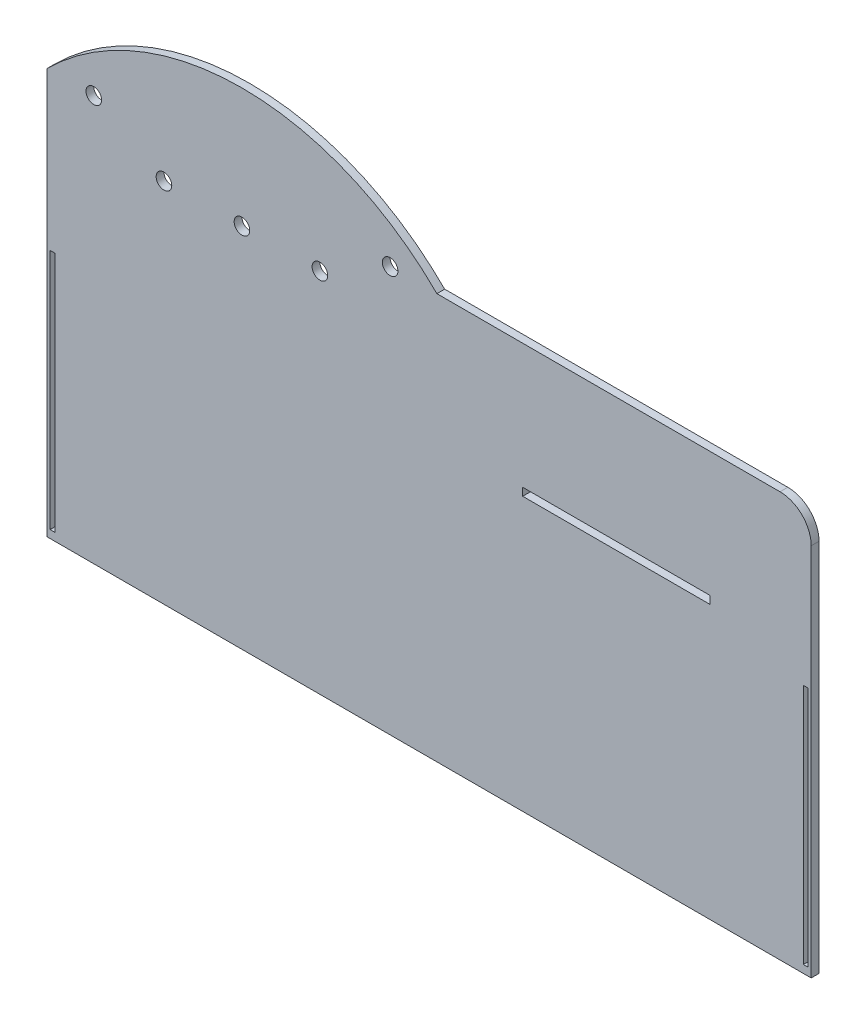
from build123d import *

# Parameters (mm, degrees)
SALIENTE_EXTRUIR1_DEPTH = 6.35
CROQUIS2_W              = 152.4
CROQUIS2_H              = 6.35
CORTAR_EXTRUIR1_DEPTH   = 6.35
CROQUIS3_R              = 6.35
CORTAR_EXTRUIR2_DEPTH   = 6.35
CROQUIS4_R              = 6.35
CORTAR_EXTRUIR3_DEPTH   = 6.35
REDONDEO1_R             = 25.4
CROQUIS5_W              = 3.81
CROQUIS5_H              = 196.85
CORTAR_EXTRUIR4_DEPTH   = 6.35


with BuildPart() as part:
    # Croquis1 → Saliente-Extruir1 (new body)
    with BuildSketch(Plane.XY):
        with BuildLine():
            Line((6.35, 165.1), (311.15, 165.1))
            Line((311.15, 165.1), (311.15, -165.1))
            Line((311.15, -165.1), (-311.15, -165.1))
            Line((-311.15, -165.1), (-311.15, 165.1))
            ThreePointArc((-311.15, 165.1), (-152.4, 230.856403027), (6.35, 165.1))
        make_face()
    extrude(amount=SALIENTE_EXTRUIR1_DEPTH)

    # Croquis2 → Cortar-Extruir1 (cut)
    with BuildSketch(Plane.XY.offset(6.35)):
        with Locations((152.4, 60.325)):
            Rectangle(CROQUIS2_W, CROQUIS2_H)
    extrude(amount=-CORTAR_EXTRUIR1_DEPTH, mode=Mode.SUBTRACT)

    # Croquis3 → Cortar-Extruir2 (cut)
    with BuildSketch(Plane.XY.offset(6.35)):
        with Locations((-152.4, 133.35)):
            Circle(CROQUIS3_R)
        with Locations((-215.9, 133.35)):
            Circle(CROQUIS3_R)
        with Locations((-88.9, 133.35)):
            Circle(CROQUIS3_R)
    extrude(amount=-CORTAR_EXTRUIR2_DEPTH, mode=Mode.SUBTRACT)

    # Croquis4 → Cortar-Extruir3 (cut)
    with BuildSketch(Plane.XY.offset(6.35)):
        with Locations((-273.05, 165.1)):
            Circle(CROQUIS4_R)
        with Locations((-31.75, 165.1)):
            Circle(CROQUIS4_R)
    extrude(amount=-CORTAR_EXTRUIR3_DEPTH, mode=Mode.SUBTRACT)

    # Redondeo1
    redondeo1_edges = [part.edges().sort_by_distance(p)[0] for p in [
        (311.15, 165.1, 3.175),
    ]]
    fillet(redondeo1_edges, radius=REDONDEO1_R)

    # Croquis5 → Cortar-Extruir4 (cut)
    with BuildSketch(Plane.XY.offset(6.35)):
        with Locations((-306.705, -60.325)):
            Rectangle(CROQUIS5_W, CROQUIS5_H)
        with Locations((306.705, -60.325)):
            Rectangle(CROQUIS5_W, CROQUIS5_H)
    extrude(amount=-CORTAR_EXTRUIR4_DEPTH, mode=Mode.SUBTRACT)


solid = part.part
